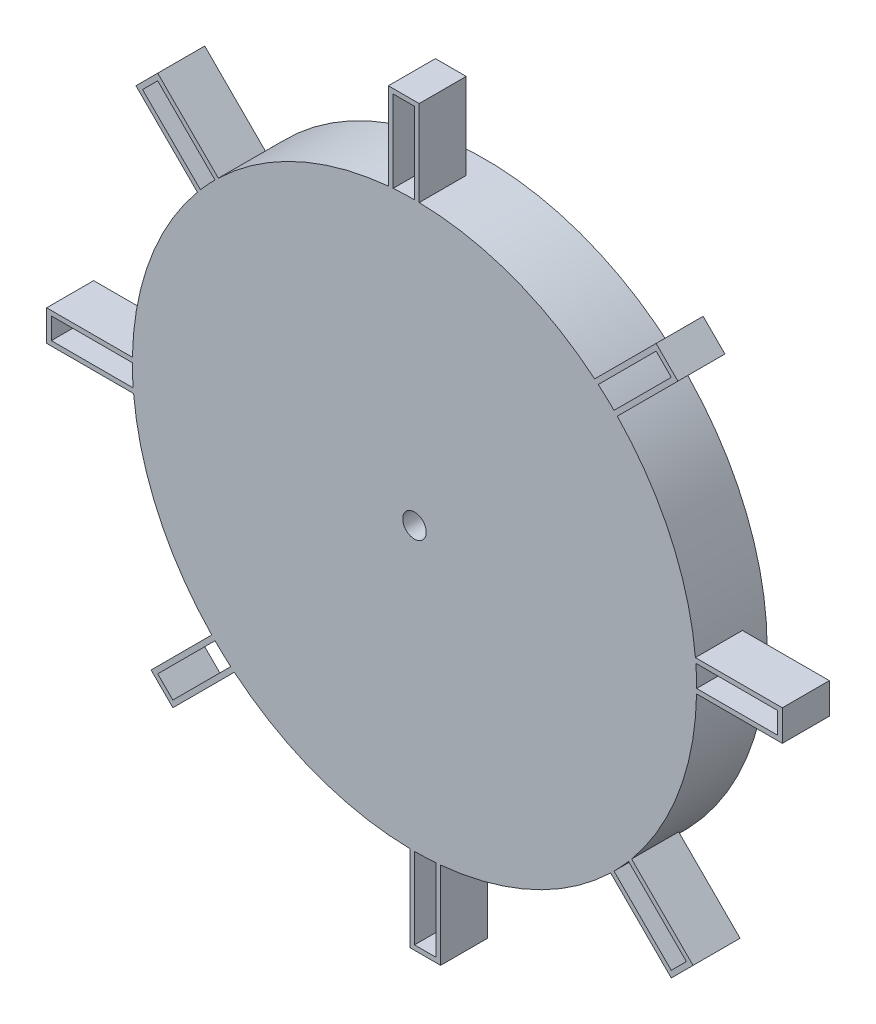
from build123d import *

# Parameters (mm, degrees)
SKETCH1_R           = 60
SKETCH1_R_2         = 2.5
BOSS_EXTRUDE1_DEPTH = 15
EXTRUDE_THIN2_DEPTH = 10


with BuildPart() as part:
    # Sketch1 → Boss-Extrude1 (new body)
    with BuildSketch(Plane.XY):
        Circle(SKETCH1_R)
        Circle(SKETCH1_R_2, mode=Mode.SUBTRACT)
    extrude(amount=BOSS_EXTRUDE1_DEPTH)

    # Sketch3 → Extrude-Thin2 (add)
    with BuildSketch(Plane.XY.offset(15)):
        with BuildLine():
            Line((-5.555158991, 58.737894145), (-5.555158991, 78.229038529))
            Line((-5.555158991, 78.229038529), (1, 78.229038529))
            Line((1, 78.229038529), (1, 58.991524815))
            ThreePointArc((1, 58.991524815), (-2.281107294, 58.95588647), (-5.555158991, 58.737894145))
        make_face()
        with BuildLine():
            Line((-4.555158991, 59.826837845), (-4.555158991, 77.229038529))
            Line((-4.555158991, 77.229038529), (0, 77.229038529))
            Line((0, 77.229038529), (0, 60))
            ThreePointArc((0, 60), (-2.27922457, 59.956693833), (-4.555158991, 59.826837845))
        make_face(mode=Mode.SUBTRACT)
        with BuildLine():
            Line((37.60587267, 45.462053855), (51.388193036, 59.244374222))
            Line((51.388193036, 59.244374222), (56.023390411, 54.609176848))
            Line((56.023390411, 54.609176848), (42.42041401, 41.006200448))
            ThreePointArc((42.42041401, 41.006200448), (40.075120678, 43.30109355), (37.60587267, 45.462053855))
        make_face()
        with BuildLine():
            Line((39.082978926, 45.524946549), (51.388193036, 57.83016066))
            Line((51.388193036, 57.83016066), (54.609176848, 54.609176848))
            Line((54.609176848, 54.609176848), (42.426406871, 42.426406871))
            ThreePointArc((42.426406871, 42.426406871), (40.784129637, 44.007439936), (39.082978926, 45.524946549))
        make_face(mode=Mode.SUBTRACT)
        with BuildLine():
            Line((58.737894145, 5.555158991), (78.229038529, 5.555158991))
            Line((78.229038529, 5.555158991), (78.229038529, -1))
            Line((78.229038529, -1), (58.991524815, -1))
            ThreePointArc((58.991524815, -1), (58.95588647, 2.281107294), (58.737894145, 5.555158991))
        make_face()
        with BuildLine():
            Line((59.826837845, 4.555158991), (77.229038529, 4.555158991))
            Line((77.229038529, 4.555158991), (77.229038529, 0))
            Line((77.229038529, 0), (60, 0))
            ThreePointArc((60, 0), (59.956693833, 2.27922457), (59.826837845, 4.555158991))
        make_face(mode=Mode.SUBTRACT)
        with BuildLine():
            Line((45.462053855, -37.60587267), (59.244374222, -51.388193036))
            Line((59.244374222, -51.388193036), (54.609176848, -56.023390411))
            Line((54.609176848, -56.023390411), (41.006200448, -42.42041401))
            ThreePointArc((41.006200448, -42.42041401), (43.30109355, -40.075120678), (45.462053855, -37.60587267))
        make_face()
        with BuildLine():
            Line((45.524946549, -39.082978926), (57.83016066, -51.388193036))
            Line((57.83016066, -51.388193036), (54.609176848, -54.609176848))
            Line((54.609176848, -54.609176848), (42.426406871, -42.426406871))
            ThreePointArc((42.426406871, -42.426406871), (44.007439936, -40.784129637), (45.524946549, -39.082978926))
        make_face(mode=Mode.SUBTRACT)
        with BuildLine():
            Line((5.555158991, -58.737894145), (5.555158991, -78.229038529))
            Line((5.555158991, -78.229038529), (-1, -78.229038529))
            Line((-1, -78.229038529), (-1, -58.991524815))
            ThreePointArc((-1, -58.991524815), (2.281107294, -58.95588647), (5.555158991, -58.737894145))
        make_face()
        with BuildLine():
            Line((4.555158991, -59.826837845), (4.555158991, -77.229038529))
            Line((4.555158991, -77.229038529), (0, -77.229038529))
            Line((0, -77.229038529), (0, -60))
            ThreePointArc((0, -60), (2.27922457, -59.956693833), (4.555158991, -59.826837845))
        make_face(mode=Mode.SUBTRACT)
        with BuildLine():
            Line((-37.60587267, -45.462053855), (-51.388193036, -59.244374222))
            Line((-51.388193036, -59.244374222), (-56.023390411, -54.609176848))
            Line((-56.023390411, -54.609176848), (-42.42041401, -41.006200448))
            ThreePointArc((-42.42041401, -41.006200448), (-40.075120678, -43.30109355), (-37.60587267, -45.462053855))
        make_face()
        with BuildLine():
            Line((-39.082978926, -45.524946549), (-51.388193036, -57.83016066))
            Line((-51.388193036, -57.83016066), (-54.609176848, -54.609176848))
            Line((-54.609176848, -54.609176848), (-42.426406871, -42.426406871))
            ThreePointArc((-42.426406871, -42.426406871), (-40.784129637, -44.007439936), (-39.082978926, -45.524946549))
        make_face(mode=Mode.SUBTRACT)
        with BuildLine():
            Line((-58.737894145, -5.555158991), (-78.229038529, -5.555158991))
            Line((-78.229038529, -5.555158991), (-78.229038529, 1))
            Line((-78.229038529, 1), (-58.991524815, 1))
            ThreePointArc((-58.991524815, 1), (-58.95588647, -2.281107294), (-58.737894145, -5.555158991))
        make_face()
        with BuildLine():
            Line((-59.826837845, -4.555158991), (-77.229038529, -4.555158991))
            Line((-77.229038529, -4.555158991), (-77.229038529, 0))
            Line((-77.229038529, 0), (-60, 0))
            ThreePointArc((-60, 0), (-59.956693833, -2.27922457), (-59.826837845, -4.555158991))
        make_face(mode=Mode.SUBTRACT)
        with BuildLine():
            Line((-45.462053855, 37.60587267), (-59.244374222, 51.388193036))
            Line((-59.244374222, 51.388193036), (-54.609176848, 56.023390411))
            Line((-54.609176848, 56.023390411), (-41.006200448, 42.42041401))
            ThreePointArc((-41.006200448, 42.42041401), (-43.30109355, 40.075120678), (-45.462053855, 37.60587267))
        make_face()
        with BuildLine():
            Line((-45.524946549, 39.082978926), (-57.83016066, 51.388193036))
            Line((-57.83016066, 51.388193036), (-54.609176848, 54.609176848))
            Line((-54.609176848, 54.609176848), (-42.426406871, 42.426406871))
            ThreePointArc((-42.426406871, 42.426406871), (-44.007439936, 40.784129637), (-45.524946549, 39.082978926))
        make_face(mode=Mode.SUBTRACT)
    extrude(amount=-EXTRUDE_THIN2_DEPTH)


solid = part.part
